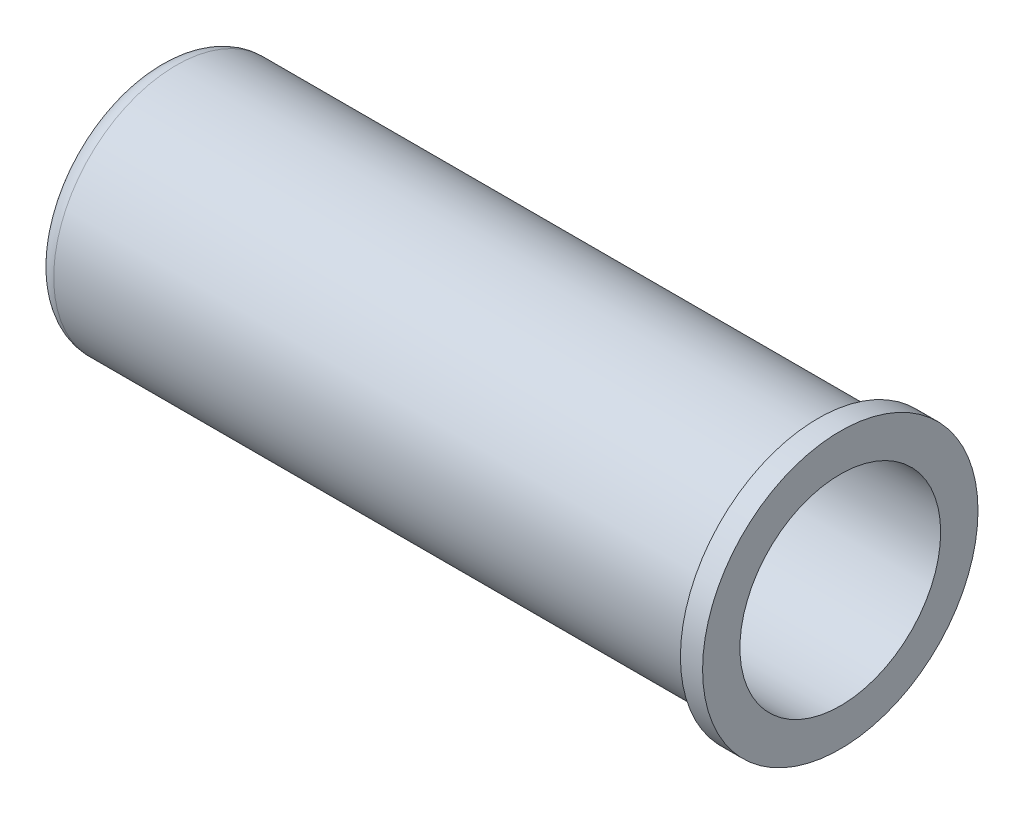
from build123d import *


with BuildPart() as part:
    # Esquisse1 → Révolution1 (revolve)
    with BuildSketch(Plane.XY):
        with BuildLine():
            Line((0, 4.3), (-27.5, 4.3))
            ThreePointArc((-27.5, 4.3), (-28.065685425, 4.065685425), (-28.3, 3.5))
            Line((-28.3, 3.5), (-28.3, 3.35))
            Line((-28.3, 3.35), (-29.25, 3.35))
            Line((-29.25, 3.35), (-29.25, 4.45))
            ThreePointArc((-29.25, 4.45), (-29.015685425, 5.015685425), (-28.45, 5.25))
            Line((-28.45, 5.25), (-0.95, 5.25))
            Line((-0.95, 5.25), (-0.95, 5.9))
            Line((-0.95, 5.9), (0, 5.9))
            Line((0, 5.9), (0, 5.25))
            Line((0, 5.25), (0, 4.3))
        make_face()
    revolve(axis=Axis((0, 0, 0), (-1, 0, 0)))


solid = part.part
